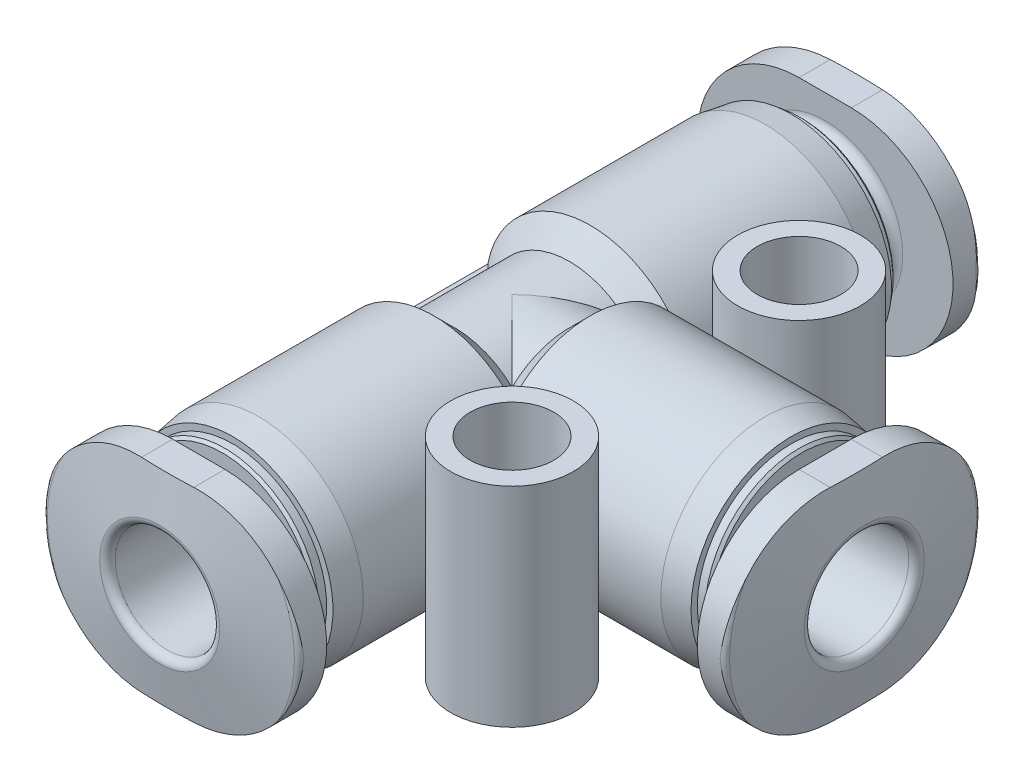
from build123d import *

# Parameters (mm, degrees)
SKETCH2_W                = 40
SKETCH2_H                = 40
CUT_EXTRUDE1_DEPTH       = 1.5
SKETCH3_W                = 40
SKETCH3_H                = 40
CUT_EXTRUDE2_DEPTH       = 1.5
SKETCH5_W                = 40
SKETCH5_H                = 40
CUT_EXTRUDE3_DEPTH       = 1.5
BOSS_EXTRUDE1_DEPTH      = 3
BOSS_EXTRUDE1_DEPTH_BACK = 3
SKETCH7_W                = 2.35
SKETCH7_H                = 8
SKETCH8_W                = 2.35
SKETCH8_H                = 8
SKETCH9_W                = 1.6
SKETCH9_H                = 8
SKETCH10_W               = 1.6
SKETCH10_H               = 8


with BuildPart() as part:
    # Sketch1 → Revolve1 (revolve)
    with BuildSketch(Plane(origin=(0, 0, 0), x_dir=(0, 0, -1), z_dir=(1, 0, 0))):
        with BuildLine():
            Line((-13.5, 0), (-13.5, 2.3))
            Line((-13.5, 2.3), (-13.070691475, 4.734729636))
            ThreePointArc((-13.070691475, 4.734729636), (-13.002287446, 4.853208889), (-12.873729924, 4.9))
            Line((-12.873729924, 4.9), (-12, 4.9))
            Line((-12, 4.9), (-12, 2.975))
            ThreePointArc((-12, 2.975), (-11.890165043, 2.709834957), (-11.625, 2.6))
            Line((-11.625, 2.6), (-11.1, 2.6))
            Line((-11.1, 2.6), (-11.1, 3.5))
            Line((-11.1, 3.5), (-11, 3.6))
            Line((-11, 3.6), (-10.7, 3.6))
            Line((-10.7, 3.6), (-10.7, 3.84161556))
            Line((-10.7, 3.84161556), (-9.7, 4))
            Line((-9.7, 4), (-3, 4))
            Line((-3, 4), (-2.2, 3.2))
            Line((-2.2, 3.2), (2.2, 3.2))
            Line((2.2, 3.2), (3, 4))
            Line((3, 4), (9.7, 4))
            Line((9.7, 4), (10.7, 3.84161556))
            Line((10.7, 3.84161556), (10.7, 3.6))
            Line((10.7, 3.6), (11, 3.6))
            Line((11, 3.6), (11.1, 3.5))
            Line((11.1, 3.5), (11.1, 2.6))
            Line((11.1, 2.6), (11.625, 2.6))
            ThreePointArc((11.625, 2.6), (11.890165043, 2.709834957), (12, 2.975))
            Line((12, 2.975), (12, 4.9))
            Line((12, 4.9), (12.873729924, 4.9))
            ThreePointArc((12.873729924, 4.9), (13.002287446, 4.853208889), (13.070691475, 4.734729636))
            Line((13.070691475, 4.734729636), (13.5, 2.3))
            Line((13.5, 2.3), (13.5, 0))
            Line((13.5, 0), (-13.5, 0))
        make_face()
    revolve(axis=Axis((0, 0, -13.5), (0, 0, 1)))

    # Sketch2 → Cut-Extrude1 (cut)
    with BuildSketch(Plane.XY.offset(-13.5)):
        Rectangle(SKETCH2_W, SKETCH2_H)
        with BuildLine():
            Line((-1, -3.9), (1, -3.9))
            ThreePointArc((1, -3.9), (4.9, 0), (1, 3.9))
            Line((1, 3.9), (-1, 3.9))
            ThreePointArc((-1, 3.9), (-4.9, 0), (-1, -3.9))
        make_face(mode=Mode.SUBTRACT)
    extrude(amount=CUT_EXTRUDE1_DEPTH, mode=Mode.SUBTRACT)

    # Sketch3 → Cut-Extrude2 (cut)
    with BuildSketch(Plane.XY.offset(13.5)):
        Rectangle(SKETCH3_W, SKETCH3_H)
        with BuildLine():
            Line((-1, -3.9), (1, -3.9))
            ThreePointArc((1, -3.9), (4.9, 0), (1, 3.9))
            Line((1, 3.9), (-1, 3.9))
            ThreePointArc((-1, 3.9), (-4.9, 0), (-1, -3.9))
        make_face(mode=Mode.SUBTRACT)
    extrude(amount=-CUT_EXTRUDE2_DEPTH, mode=Mode.SUBTRACT)

    # Sketch4 → Revolve2 (revolve)
    with BuildSketch(Plane(origin=(0, 0, 0), x_dir=(1, 0, 0), z_dir=(0, 1, 0))):
        with BuildLine():
            Line((0, 0), (0, 3.2))
            Line((0, 3.2), (2.2, 3.2))
            Line((2.2, 3.2), (3, 4))
            Line((3, 4), (9.7, 4))
            Line((9.7, 4), (10.7, 3.84161556))
            Line((10.7, 3.84161556), (10.7, 3.6))
            Line((10.7, 3.6), (11, 3.6))
            Line((11, 3.6), (11.1, 3.5))
            Line((11.1, 3.5), (11.1, 2.6))
            Line((11.1, 2.6), (11.625, 2.6))
            ThreePointArc((11.625, 2.6), (11.890165043, 2.709834957), (12, 2.975))
            Line((12, 2.975), (12, 4.9))
            Line((12, 4.9), (12.873729924, 4.9))
            ThreePointArc((12.873729924, 4.9), (13.002287446, 4.853208889), (13.070691475, 4.734729636))
            Line((13.070691475, 4.734729636), (13.5, 2.3))
            Line((13.5, 2.3), (13.5, 0))
            Line((13.5, 0), (0, 0))
        make_face()
    revolve(axis=Axis((13.5, 0, 0), (-1, 0, 0)))

    # Sketch5 → Cut-Extrude3 (cut)
    with BuildSketch(Plane(origin=(13.5, 0, 0), x_dir=(0, 0, -1), z_dir=(1, 0, 0))):
        Rectangle(SKETCH5_W, SKETCH5_H)
        with BuildLine():
            Line((-1, -3.9), (1, -3.9))
            ThreePointArc((1, -3.9), (4.9, 0), (1, 3.9))
            Line((1, 3.9), (-1, 3.9))
            ThreePointArc((-1, 3.9), (-4.9, 0), (-1, -3.9))
        make_face(mode=Mode.SUBTRACT)
    extrude(amount=-CUT_EXTRUDE3_DEPTH, mode=Mode.SUBTRACT)

    # Sketch6 → Boss-Extrude1 (add, two sides)
    with BuildSketch(Plane.XY) as boss_extrude1_sk:
        with BuildLine():
            Line((-3.929058411, -0.75), (0, -0.75))
            Line((0, -0.75), (0, 0.75))
            Line((0, 0.75), (-3.929058411, 0.75))
            ThreePointArc((-3.929058411, 0.75), (-4, 0), (-3.929058411, -0.75))
        make_face()
    extrude(amount=BOSS_EXTRUDE1_DEPTH)
    extrude(boss_extrude1_sk.sketch, amount=-BOSS_EXTRUDE1_DEPTH_BACK)

    # Sketch7 → Revolve3 (revolve)
    with BuildSketch(Plane(origin=(5.5, 0, 0), x_dir=(0, 0, -1), z_dir=(1, 0, 0))):
        with Locations((-6.675, 0)):
            Rectangle(SKETCH7_W, SKETCH7_H)
    revolve(axis=Axis((5.5, 4, 5.5), (0, -1, 0)))

    # Sketch8 → Revolve4 (revolve)
    with BuildSketch(Plane(origin=(5.5, 0, 0), x_dir=(0, 0, -1), z_dir=(1, 0, 0))):
        with Locations((4.325, 0)):
            Rectangle(SKETCH8_W, SKETCH8_H)
    revolve(axis=Axis((5.5, 4, -5.5), (0, -1, 0)))

    # Sketch9 → Cut-Revolve1 (revolve, cut)
    with BuildSketch(Plane(origin=(5.5, 0, 0), x_dir=(0, 0, -1), z_dir=(1, 0, 0))):
        with Locations((-6.3, 0)):
            Rectangle(SKETCH9_W, SKETCH9_H)
    revolve(axis=Axis((5.5, 4, 5.5), (0, -1, 0)), mode=Mode.SUBTRACT)

    # Sketch10 → Cut-Revolve2 (revolve, cut)
    with BuildSketch(Plane(origin=(5.5, 0, 0), x_dir=(0, 0, -1), z_dir=(1, 0, 0))):
        with Locations((4.7, 0)):
            Rectangle(SKETCH10_W, SKETCH10_H)
    revolve(axis=Axis((5.5, 4, -5.5), (0, -1, 0)), mode=Mode.SUBTRACT)

    # Sketch11 → Cut-Revolve3 (revolve, cut)
    with BuildSketch(Plane(origin=(0, 0, 0), x_dir=(0, 0, -1), z_dir=(1, 0, 0))):
        with BuildLine():
            Line((-13.5, 0), (-13.5, 2.3))
            ThreePointArc((-13.5, 2.3), (-13.412132034, 2.087867966), (-13.2, 2))
            Line((-13.2, 2), (-2.1, 2))
            ThreePointArc((-2.1, 2), (-2.029289322, 1.970710678), (-2, 1.9))
            Line((-2, 1.9), (-2, 1.5))
            Line((-2, 1.5), (2, 1.5))
            Line((2, 1.5), (2, 1.9))
            ThreePointArc((2, 1.9), (2.029289322, 1.970710678), (2.1, 2))
            Line((2.1, 2), (13.2, 2))
            ThreePointArc((13.2, 2), (13.412132034, 2.087867966), (13.5, 2.3))
            Line((13.5, 2.3), (13.5, 0))
            Line((13.5, 0), (-13.5, 0))
        make_face()
    revolve(axis=Axis((0, 0, -13.5), (0, 0, 1)), mode=Mode.SUBTRACT)

    # Sketch12 → Cut-Revolve4 (revolve, cut)
    with BuildSketch(Plane(origin=(0, 0, 0), x_dir=(1, 0, 0), z_dir=(0, 1, 0))):
        with BuildLine():
            Line((0, 0), (0, 1.5))
            Line((0, 1.5), (2, 1.5))
            Line((2, 1.5), (2, 1.9))
            ThreePointArc((2, 1.9), (2.029289322, 1.970710678), (2.1, 2))
            Line((2.1, 2), (13.2, 2))
            ThreePointArc((13.2, 2), (13.412132034, 2.087867966), (13.5, 2.3))
            Line((13.5, 2.3), (13.5, 0))
            Line((13.5, 0), (0, 0))
        make_face()
    revolve(axis=Axis((13.5, 0, 0), (-1, 0, 0)), mode=Mode.SUBTRACT)


solid = part.part
